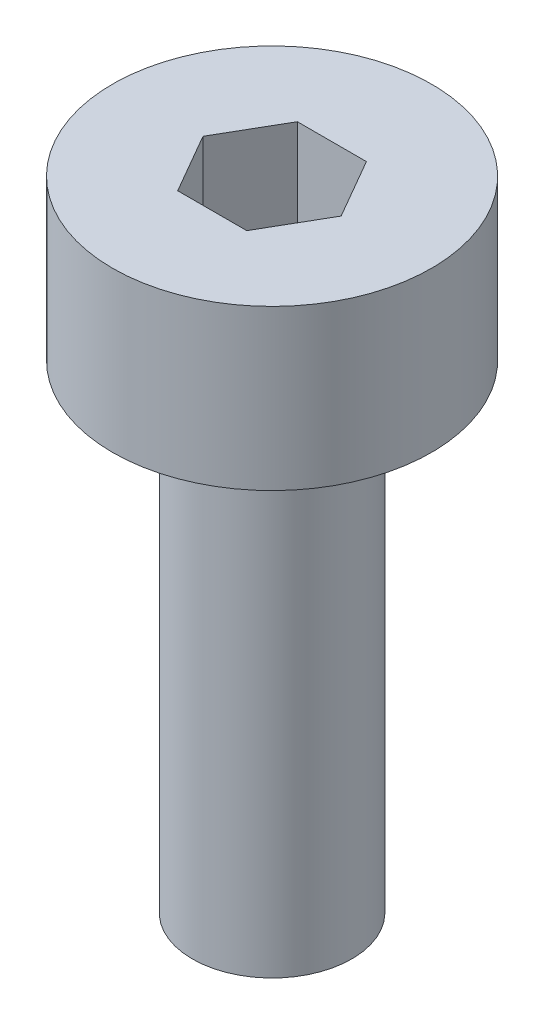
from build123d import *

# Parameters (mm, degrees)
SKETCH1_R           = 2
BOSS_EXTRUDE1_DEPTH = 12
SKETCH2_R           = 4
BOSS_EXTRUDE2_DEPTH = 4
CUT_EXTRUDE1_DEPTH  = 2.5


with BuildPart() as part:
    # Sketch1 → Boss-Extrude1 (new body)
    with BuildSketch(Plane(origin=(0, 0, 0), x_dir=(1, 0, 0), z_dir=(0, 1, 0))):
        Circle(SKETCH1_R)
    extrude(amount=BOSS_EXTRUDE1_DEPTH)

    # Sketch2 → Boss-Extrude2 (add)
    with BuildSketch(Plane(origin=(0, 12, 0), x_dir=(1, 0, 0), z_dir=(0, 1, 0))):
        Circle(SKETCH2_R)
    extrude(amount=BOSS_EXTRUDE2_DEPTH)

    # Sketch3 → Cut-Extrude1 (cut)
    with BuildSketch(Plane(origin=(0, 16, 0), x_dir=(1, 0, 0), z_dir=(0, 1, 0))):
        Polygon((1.732050808, 0), (0.866025404, 1.5), (-0.866025404, 1.5), (-1.732050808, 0), (-0.866025404, -1.5), (0.866025404, -1.5), align=None)
    extrude(amount=-CUT_EXTRUDE1_DEPTH, mode=Mode.SUBTRACT)


solid = part.part
